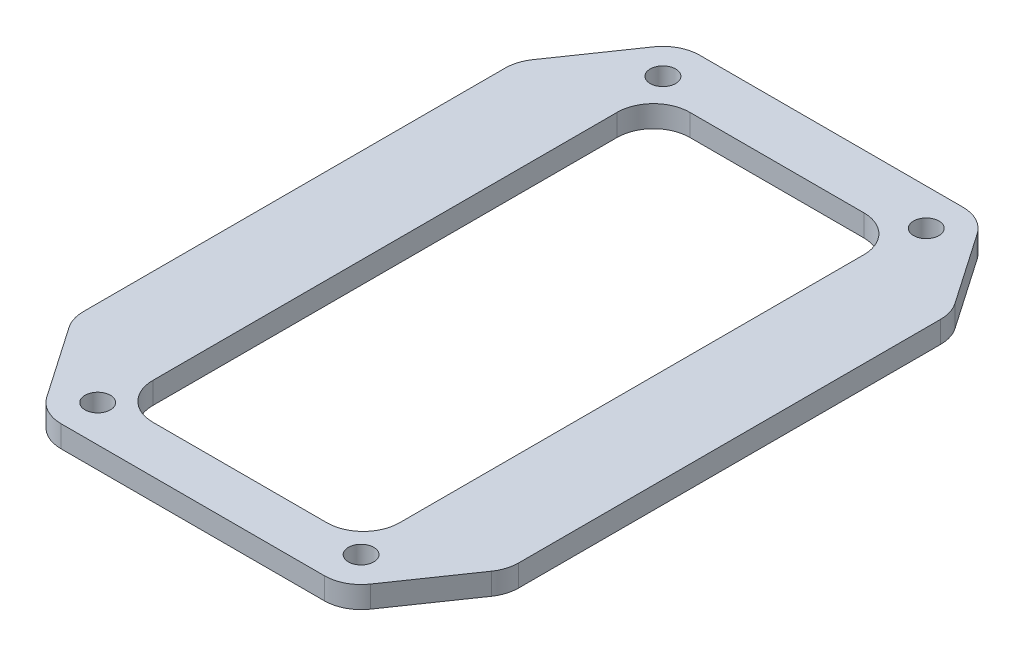
from build123d import *

# Parameters (mm, degrees)
SKETCH1_W           = 60
SKETCH1_H           = 88
SKETCH1_R           = 1.75
SKETCH1_W_2         = 34
SKETCH1_H_2         = 74
BOSS_EXTRUDE1_DEPTH = 3
FILLET1_R           = 5
SKETCH6_W           = 62
SKETCH6_H           = 90
CUT_EXTRUDE3_DEPTH  = 4
FILLET3_R           = 5.05


with BuildPart() as part:
    # Sketch1 → Boss-Extrude1 (new body)
    with BuildSketch(Plane(origin=(0, 0, 0), x_dir=(1, 0, 0), z_dir=(0, 1, 0))):
        with Locations((30, 44)):
            Rectangle(SKETCH1_W, SKETCH1_H)
        with Locations((11.85, 82.95)):
            Circle(SKETCH1_R, mode=Mode.SUBTRACT)
        with Locations((48.15, 82.95)):
            Circle(SKETCH1_R, mode=Mode.SUBTRACT)
        with Locations((48.15, 5.05)):
            Circle(SKETCH1_R, mode=Mode.SUBTRACT)
        with Locations((11.85, 5.05)):
            Circle(SKETCH1_R, mode=Mode.SUBTRACT)
        with Locations((30, 43.5)):
            Rectangle(SKETCH1_W_2, SKETCH1_H_2, mode=Mode.SUBTRACT)
    extrude(amount=BOSS_EXTRUDE1_DEPTH)

    # Fillet1
    fillet1_edges = [part.edges().sort_by_distance(p)[0] for p in [
        (13, 1.5, -80.5),
        (13, 1.5, -6.5),
        (47, 1.5, -6.5),
        (47, 1.5, -80.5),
    ]]
    fillet(fillet1_edges, radius=FILLET1_R)

    # Sketch6 → Cut-Extrude3 (cut, through all)
    with BuildSketch(Plane(origin=(0, 3, 0), x_dir=(1, 0, 0), z_dir=(0, 1, 0))):
        with Locations((30, 44)):
            Rectangle(SKETCH6_W, SKETCH6_H)
        Polygon((9.196567368, 88), (0, 74.65), (0, 13.35), (9.196567368, 0), (50.803432632, 0), (60, 13.35), (60, 74.65), (50.803432632, 88), align=None, mode=Mode.SUBTRACT)
    extrude(amount=-CUT_EXTRUDE3_DEPTH, mode=Mode.SUBTRACT)

    # Fillet3
    fillet3_edges = [part.edges().sort_by_distance(p)[0] for p in [
        (0, 1.5, -74.65),
        (9.196567368, 1.5, -88),
        (50.803432632, 1.5, -88),
        (60, 1.5, -74.65),
        (60, 1.5, -13.35),
        (50.803432632, 1.5, 0),
        (9.196567368, 1.5, 0),
        (0, 1.5, -13.35),
    ]]
    fillet(fillet3_edges, radius=FILLET3_R)


solid = part.part
